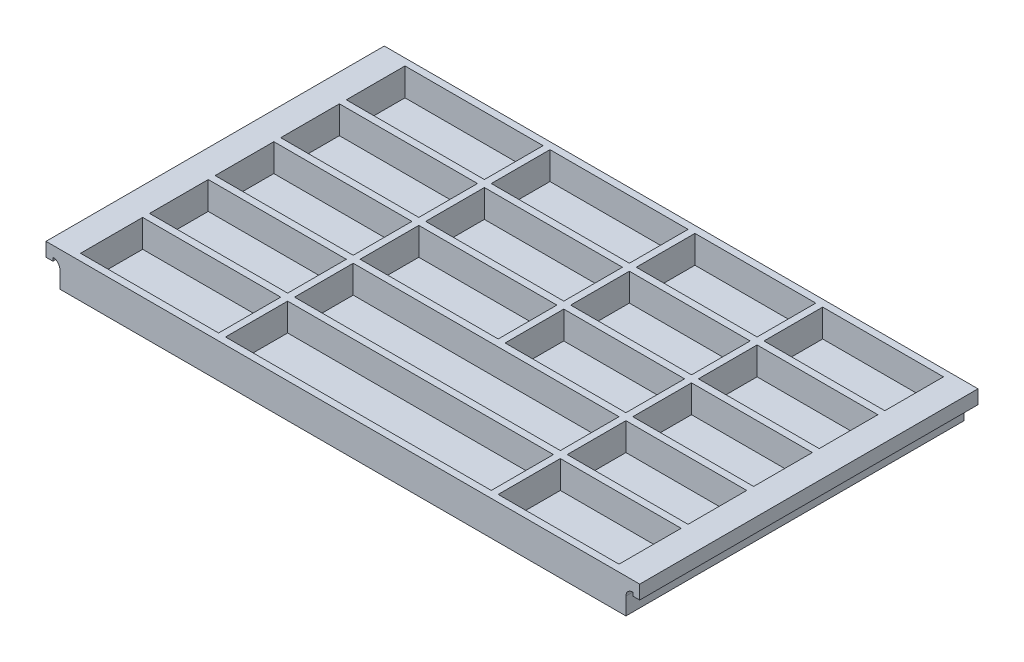
from build123d import *

# Parameters (mm, degrees)
SKETCH1_W    = 203.2
SKETCH1_H    = 124.46
SKETCH1_W_2  = 50.8
SKETCH1_H_2  = 22.86
SKETCH1_H_3  = 21.59
SKETCH1_W_3  = 97.79
SKETCH1_W_4  = 44.45
TRAY_DEPTH   = 10.16
SKETCH3_W    = 203.2
SKETCH3_H    = 124.46
BASE_DEPTH   = 2.54
HANDLE_DEPTH = 124.46


with BuildPart() as part:
    # Sketch1 → tray (new body)
    with BuildSketch(Plane(origin=(0, 0, 0), x_dir=(1, 0, 0), z_dir=(0, 1, 0))):
        Rectangle(SKETCH1_W, SKETCH1_H)
        with Locations((-73.66, -48.26)):
            Rectangle(SKETCH1_W_2, SKETCH1_H_2, mode=Mode.SUBTRACT)
        with Locations((-73.66, -23.495)):
            Rectangle(SKETCH1_W_2, SKETCH1_H_3, mode=Mode.SUBTRACT)
        with Locations((3.175, -48.26)):
            Rectangle(SKETCH1_W_3, SKETCH1_H_2, mode=Mode.SUBTRACT)
        with Locations((76.835, -48.26)):
            Rectangle(SKETCH1_W_4, SKETCH1_H_2, mode=Mode.SUBTRACT)
        Polygon((-45.72, -34.29), (-45.72, -12.7), (5.08, -12.7), (52.07, -12.7), (52.07, -34.29), (5.08, -34.29), align=None, mode=Mode.SUBTRACT)
        with Locations((76.835, -23.495)):
            Rectangle(SKETCH1_W_4, SKETCH1_H_3, mode=Mode.SUBTRACT)
        with Locations((-73.66, 0.635)):
            Rectangle(SKETCH1_W_2, SKETCH1_H_3, mode=Mode.SUBTRACT)
        with Locations((-73.66, 24.765)):
            Rectangle(SKETCH1_W_2, SKETCH1_H_3, mode=Mode.SUBTRACT)
        with Locations((-20.32, 0.635)):
            Rectangle(SKETCH1_W_2, SKETCH1_H_3, mode=Mode.SUBTRACT)
        with Locations((-20.32, 24.765)):
            Rectangle(SKETCH1_W_2, SKETCH1_H_3, mode=Mode.SUBTRACT)
        with Locations((-73.66, 48.895)):
            Rectangle(SKETCH1_W_2, SKETCH1_H_3, mode=Mode.SUBTRACT)
        with Locations((-20.32, 48.895)):
            Rectangle(SKETCH1_W_2, SKETCH1_H_3, mode=Mode.SUBTRACT)
        with Locations((29.845, 0.635)):
            Rectangle(SKETCH1_W_4, SKETCH1_H_3, mode=Mode.SUBTRACT)
        with Locations((29.845, 24.765)):
            Rectangle(SKETCH1_W_4, SKETCH1_H_3, mode=Mode.SUBTRACT)
        with Locations((76.835, 0.635)):
            Rectangle(SKETCH1_W_4, SKETCH1_H_3, mode=Mode.SUBTRACT)
        with Locations((76.835, 24.765)):
            Rectangle(SKETCH1_W_4, SKETCH1_H_3, mode=Mode.SUBTRACT)
        with Locations((29.845, 48.895)):
            Rectangle(SKETCH1_W_4, SKETCH1_H_3, mode=Mode.SUBTRACT)
        with Locations((76.835, 48.895)):
            Rectangle(SKETCH1_W_4, SKETCH1_H_3, mode=Mode.SUBTRACT)
    extrude(amount=TRAY_DEPTH)

    # Sketch3 → base (add)
    with BuildSketch(Plane(origin=(0, 0, 0), x_dir=(-1, 0, 0), z_dir=(0, -1, 0))):
        Rectangle(SKETCH3_W, SKETCH3_H)
    extrude(amount=BASE_DEPTH)

    # Sketch4 → handle (add)
    with BuildSketch(Plane.XY.offset(62.23)):
        with BuildLine():
            Line((-101.6, -2.54), (-101.6, 10.16))
            Line((-101.6, 10.16), (-109.22, 10.16))
            Line((-109.22, 10.16), (-109.22, 5.08))
            Line((-109.22, 5.08), (-106.68, 5.08))
            Line((-106.68, 5.08), (-106.68, 6.35))
            ThreePointArc((-106.68, 6.35), (-104.883948776, 5.606051224), (-104.14, 3.81))
            Line((-104.14, 3.81), (-104.14, -2.54))
            Line((-104.14, -2.54), (-101.6, -2.54))
        make_face()
        with BuildLine():
            Line((101.6, -2.54), (104.14, -2.54))
            Line((104.14, -2.54), (104.14, 3.81))
            ThreePointArc((104.14, 3.81), (104.883948776, 5.606051224), (106.68, 6.35))
            Line((106.68, 6.35), (106.68, 5.08))
            Line((106.68, 5.08), (109.22, 5.08))
            Line((109.22, 5.08), (109.22, 10.16))
            Line((109.22, 10.16), (101.6, 10.16))
            Line((101.6, 10.16), (101.6, -2.54))
        make_face()
    extrude(amount=-HANDLE_DEPTH)


solid = part.part
